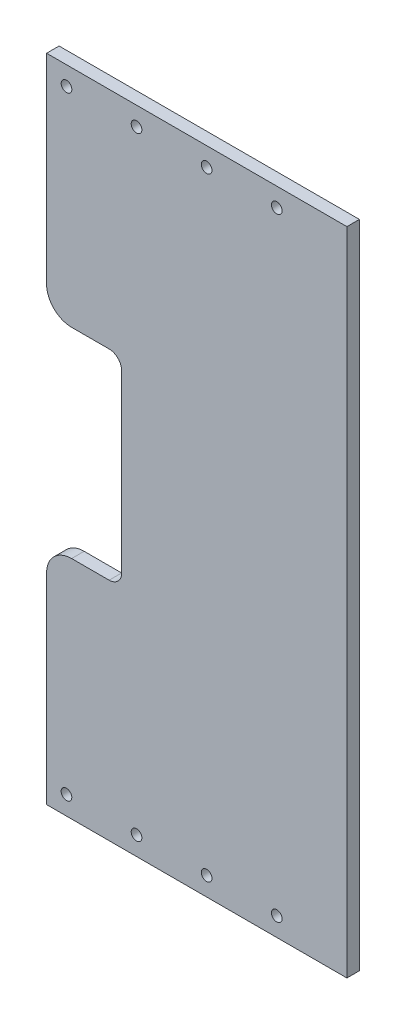
from build123d import *

# Parameters (mm, degrees)
SKETCH1_R           = 1.352550752
SKETCH1_RX          = 1.35255
SKETCH1_RY          = 1.352549248
BOSS_EXTRUDE2_DEPTH = 3.175


with BuildPart() as part:
    # Sketch1 → Boss-Extrude2 (new body)
    with BuildSketch(Plane.XY):
        with BuildLine():
            Line((38.098244435, 82.55), (38.098416123, -82.55))
            Line((38.098416123, -82.55), (-38.098244435, -82.55))
            Line((-38.098244435, -82.55), (-38.098244435, -31.651036949))
            add(Edge.make_bspline(
                [(-31.748247963, -25.301036949), (-38.098244435, -25.301036949), (-38.098244435, -31.651036949)],
                knots=[3.141592654, 3.141592654, 3.141592654, 4.71238898, 4.71238898, 4.71238898], degree=2, weights=[1, 0.707106781, 1]))
            Line((-31.748247963, -25.301036949), (-22.223253256, -25.301036949))
            add(Edge.make_bspline(
                [(-22.223253256, -25.301036949), (-19.04825502, -25.301036949), (-19.04825502, -22.126036949)],
                knots=[3.141592654, 3.141592654, 3.141592654, 4.71238898, 4.71238898, 4.71238898], degree=2, weights=[1, 0.707106781, 1]))
            Line((-19.04825502, -22.126036949), (-19.04825502, 22.323963051))
            add(Edge.make_bspline(
                [(-19.04825502, 22.323963051), (-19.04825502, 25.498963051), (-22.223253256, 25.498963051)],
                knots=[4.71238898, 4.71238898, 4.71238898, 6.283185307, 6.283185307, 6.283185307], degree=2, weights=[1, 0.707106781, 1]))
            Line((-22.223253256, 25.498963051), (-31.748247963, 25.498963051))
            add(Edge.make_bspline(
                [(-38.098244435, 31.848963051), (-38.098244435, 25.498963051), (-31.748247963, 25.498963051)],
                knots=[4.71238898, 4.71238898, 4.71238898, 6.283185307, 6.283185307, 6.283185307], degree=2, weights=[1, 0.707106781, 1]))
            Line((-38.098244435, 31.848963051), (-38.098244435, 82.55))
            Line((-38.098244435, 82.55), (38.098244435, 82.55))
        make_face()
        with Locations((2.505261643, -77.7875)):
            Circle(SKETCH1_R, mode=Mode.SUBTRACT)
        with Locations((-15.274748237, -77.7875)):
            Circle(SKETCH1_R, mode=Mode.SUBTRACT)
        with Locations((-33.054758116, -77.7875)):
            Circle(SKETCH1_R, mode=Mode.SUBTRACT)
        with Locations((2.505089955, 77.7875)):
            Circle(SKETCH1_R, mode=Mode.SUBTRACT)
        with Locations((-15.274919924, 77.7875)):
            Circle(SKETCH1_R, mode=Mode.SUBTRACT)
        with Locations(Location((20.298314341, -77.7875), (0, 0, -90))):
            Ellipse(SKETCH1_RX, SKETCH1_RY, mode=Mode.SUBTRACT)
        with Locations(Location((20.298142653, 77.7875), (0, 0, -90))):
            Ellipse(SKETCH1_RX, SKETCH1_RY, mode=Mode.SUBTRACT)
        with Locations(Location((-33.041827709, 77.7875), (0, 0, -90))):
            Ellipse(SKETCH1_RX, SKETCH1_RY, mode=Mode.SUBTRACT)
    extrude(amount=BOSS_EXTRUDE2_DEPTH)


solid = part.part
